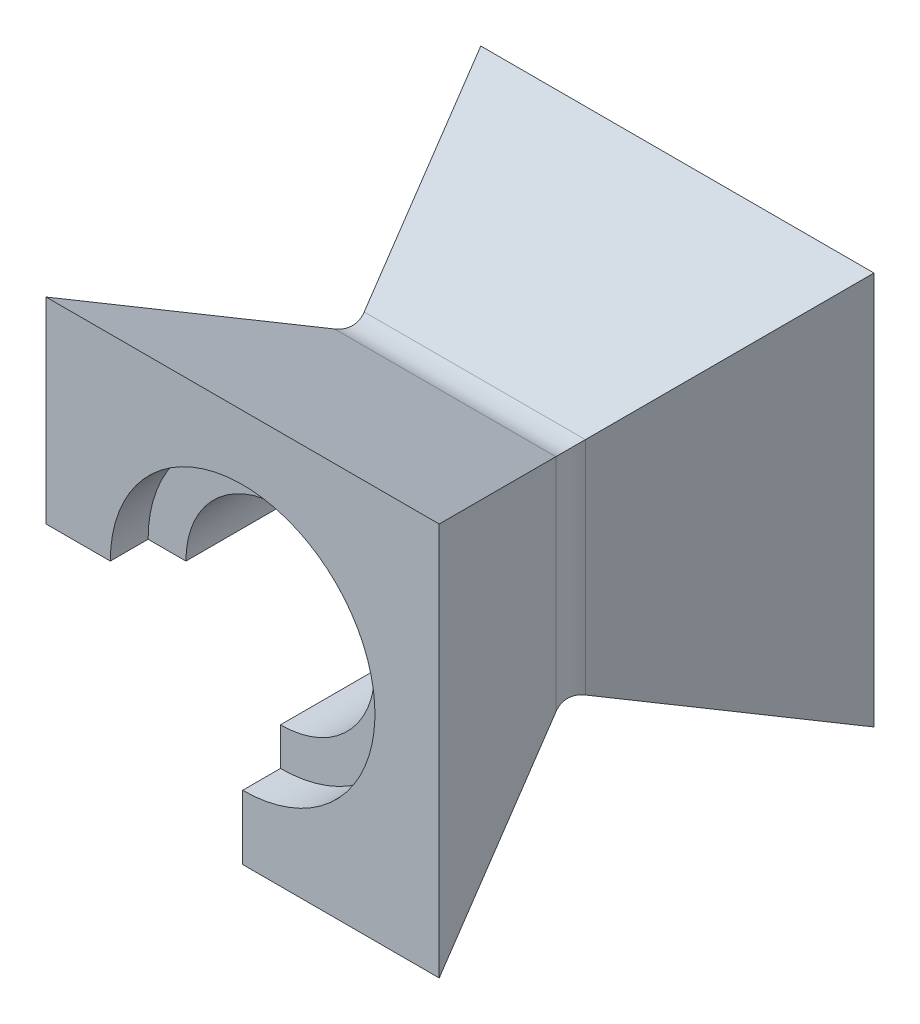
from build123d import *

# Parameters (mm, degrees)
SKETCH1_W           = 104
SKETCH1_H           = 104
SKETCH1_R           = 25
BOSS_EXTRUDE1_DEPTH = 115
CUT_EXTRUDE3_DEPTH  = 115
CUT_EXTRUDE4_DEPTH  = 115
SKETCH8_W           = 63.18137864
SKETCH8_H           = 61.36622301
CUT_EXTRUDE5_DEPTH  = 116
FILLET1_R           = 10
SKETCH10_R          = 35
CUT_EXTRUDE6_DEPTH  = 10
SKETCH9_R           = 35
CUT_EXTRUDE7_DEPTH  = 10


with BuildPart() as part:
    # Sketch1 → Boss-Extrude1 (new body)
    with BuildSketch(Plane.XY):
        Rectangle(SKETCH1_W, SKETCH1_H)
        Circle(SKETCH1_R, mode=Mode.SUBTRACT)
    extrude(amount=BOSS_EXTRUDE1_DEPTH)

    # Sketch7 → Cut-Extrude3 (cut)
    with BuildSketch(Plane.ZY.offset(52)):
        Polygon((0, 52), (115, 52), (57.5, 27.592698068), align=None)
        Polygon((0, -52), (115, -52), (57.5, -27.592698068), align=None)
    extrude(amount=-CUT_EXTRUDE3_DEPTH, mode=Mode.SUBTRACT)

    # Sketch4 → Cut-Extrude4 (cut)
    with BuildSketch(Plane(origin=(0, 52, 0), x_dir=(1, 0, 0), z_dir=(0, 1, 0))):
        Polygon((-52, 0), (-27.592698068, -57.5), (-52, -115), align=None)
        Polygon((52, -115), (27.592698068, -57.5), (52, 0), align=None)
    extrude(amount=-CUT_EXTRUDE4_DEPTH, mode=Mode.SUBTRACT)

    # Sketch8 → Cut-Extrude5 (cut, through all)
    with BuildSketch(Plane(origin=(0, 0, 0), x_dir=(-1, 0, 0), z_dir=(0, 0, -1))):
        with Locations((31.59068932, -30.683111505)):
            Rectangle(SKETCH8_W, SKETCH8_H)
    extrude(amount=-CUT_EXTRUDE5_DEPTH, mode=Mode.SUBTRACT)

    # Fillet1
    fillet1_edges = [part.edges().sort_by_distance(p)[0] for p in [
        (13.796349034, -27.592698068, 57.5),
        (0, 27.592698068, 57.5),
        (27.592698068, 0, 57.5),
        (-27.592698068, 13.796349034, 57.5),
    ]]
    fillet(fillet1_edges, radius=FILLET1_R)

    # Sketch10 → Cut-Extrude6 (cut)
    with BuildSketch(Plane.XY.offset(115)):
        Circle(SKETCH10_R)
    extrude(amount=-CUT_EXTRUDE6_DEPTH, mode=Mode.SUBTRACT)

    # Sketch9 → Cut-Extrude7 (cut)
    with BuildSketch(Plane(origin=(0, 0, 0), x_dir=(-1, 0, 0), z_dir=(0, 0, -1))):
        Circle(SKETCH9_R)
    extrude(amount=-CUT_EXTRUDE7_DEPTH, mode=Mode.SUBTRACT)


solid = part.part
